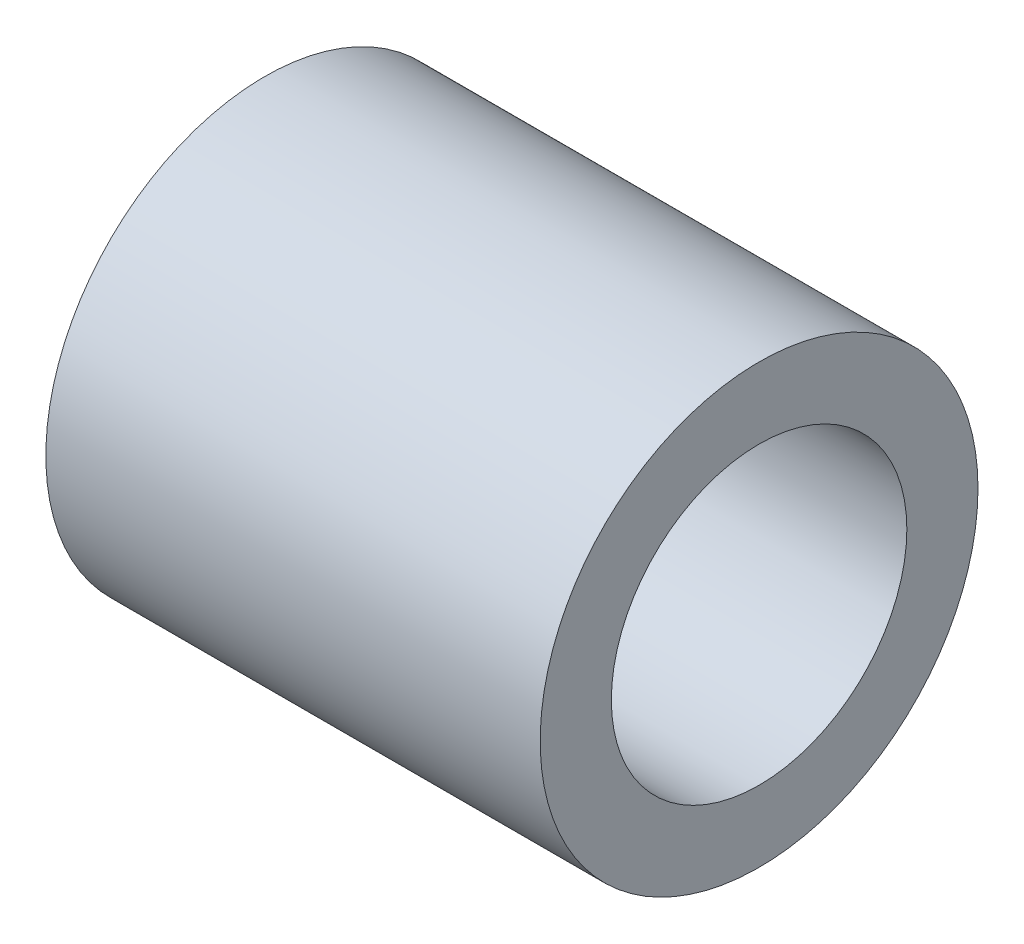
from build123d import *

# Parameters (mm, degrees)
SKETCH2_R           = 6
SKETCH2_R_2         = 4.05
BOSS_EXTRUDE1_DEPTH = 13.55


with BuildPart() as part:
    # Sketch2 → Boss-Extrude1 (new body)
    with BuildSketch(Plane(origin=(0, 0, 0), x_dir=(0, 0, -1), z_dir=(1, 0, 0))):
        Circle(SKETCH2_R)
        Circle(SKETCH2_R_2, mode=Mode.SUBTRACT)
    extrude(amount=BOSS_EXTRUDE1_DEPTH)


solid = part.part
